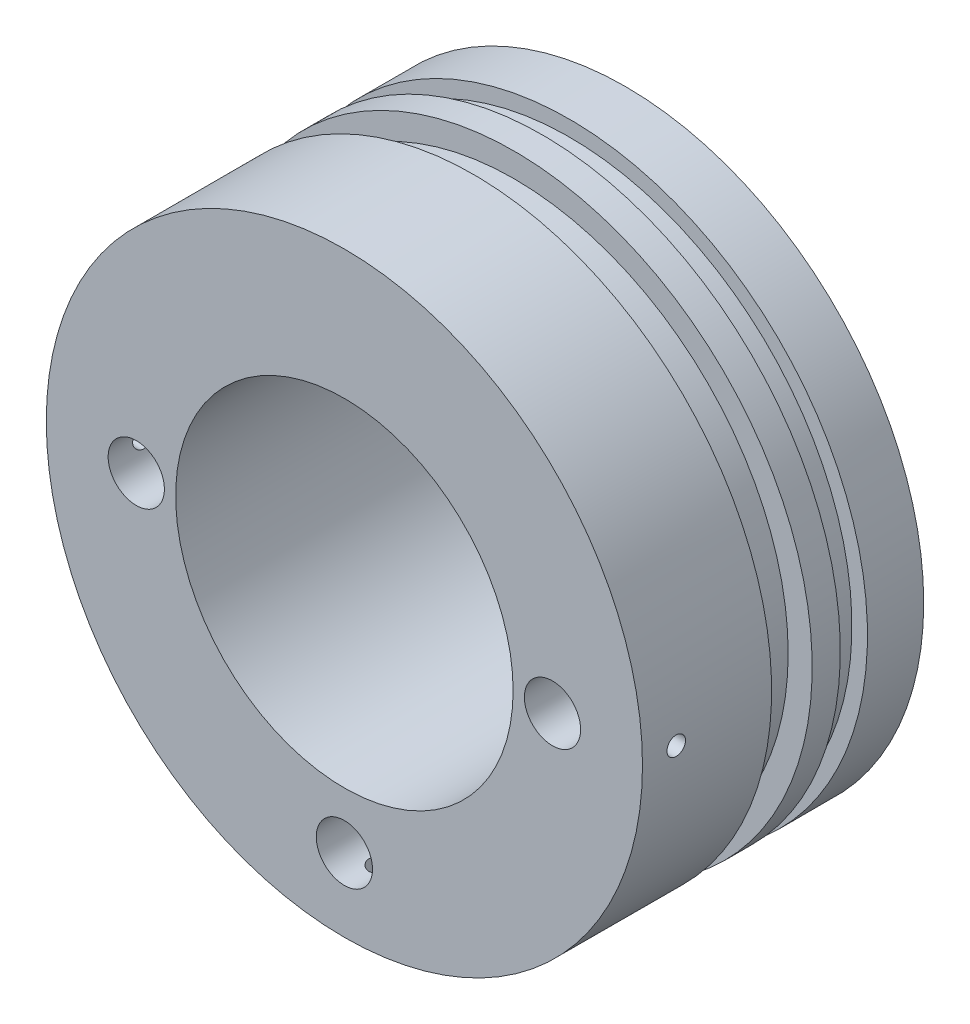
from build123d import *

# Parameters (mm, degrees)
SKETCH1_R                      = 53
BOSS_EXTRUDE1_DEPTH            = 50
F_10_0_10_DIAMETER_HOLE2_D     = 10
F_10_0_10_DIAMETER_HOLE2_DEPTH = 17.5
F_10_0_10_DIAMETER_HOLE2_TIP   = 3.004303095
M4_TAPPED_HOLE1_REACH          = 130.627
M4_TAPPED_HOLE1_BORE_R         = 1.65
CIRPATTERN1_COUNT              = 3
CIRPATTERN1_ANGLE              = 180
SKETCH11_R                     = 30
CUT_EXTRUDE2_DEPTH             = 45
SKETCH12_W                     = 4.826
SKETCH12_H                     = 2.76515
SKETCH12_W_2                   = 7.2136
SKETCH12_H_2                   = 4.27264
SKETCH14_W                     = 2.667
SKETCH14_H                     = 4.572
CIRPATTERN2_COUNT              = 4


with BuildPart() as part:
    # Sketch1 → Boss-Extrude1 (new body)
    with BuildSketch(Plane.XY):
        Circle(SKETCH1_R)
    extrude(amount=BOSS_EXTRUDE1_DEPTH)

    # Ø10.0 (10) Diameter Hole2
    with Locations(Plane.XY.offset(50)):
        with Locations((-37, 0), (37, 0), (0, -40)):
            Hole(F_10_0_10_DIAMETER_HOLE2_D / 2, depth=F_10_0_10_DIAMETER_HOLE2_DEPTH)
            with Locations((0, 0, -(F_10_0_10_DIAMETER_HOLE2_DEPTH + F_10_0_10_DIAMETER_HOLE2_TIP / 2))):  # 118° drill point
                Cone(0, F_10_0_10_DIAMETER_HOLE2_D / 2, F_10_0_10_DIAMETER_HOLE2_TIP, mode=Mode.SUBTRACT)

    # M4 Tapped Hole1 bore → M4 Tapped Hole1 (cut, up to next)
    with BuildSketch(Plane.ZY.offset(53), mode=Mode.PRIVATE) as m4_tapped_hole1_sk1:
        with Locations((44, 0)):
            Circle(M4_TAPPED_HOLE1_BORE_R)
    m4_tapped_hole1_tool1 = extrude(m4_tapped_hole1_sk1.sketch, amount=-M4_TAPPED_HOLE1_REACH, mode=Mode.PRIVATE) & part.part
    m4_tapped_hole1 = m4_tapped_hole1_tool1.solids().sort_by_distance((-53, 0, 44))[0]
    add(m4_tapped_hole1, mode=Mode.SUBTRACT)

    # CirPattern1: M4 Tapped Hole1 ×3 about axis
    cirpattern1_axis = Axis((0, 0, 50), (0, 0, 1))
    for i in range(1, CIRPATTERN1_COUNT):
        add(m4_tapped_hole1.rotate(cirpattern1_axis, i * CIRPATTERN1_ANGLE / (CIRPATTERN1_COUNT - 1)), mode=Mode.SUBTRACT)

    # Sketch11 → Cut-Extrude2 (cut)
    with BuildSketch(Plane.XY.offset(50)):
        Circle(SKETCH11_R)
    extrude(amount=-CUT_EXTRUDE2_DEPTH, mode=Mode.SUBTRACT)

    # Sketch12 → Cut-Revolve1 (revolve, cut)
    with BuildSketch(Plane(origin=(0, 0, 0), x_dir=(0, 0, -1), z_dir=(1, 0, 0)), mode=Mode.PRIVATE) as cut_revolve1_sk:
        with Locations((-12.413, 51.617425)):
            Rectangle(SKETCH12_W, SKETCH12_H)
        with Locations((-23.4328, 50.86368)):
            Rectangle(SKETCH12_W_2, SKETCH12_H_2)
    revolve(cut_revolve1_sk.sketch.rotate(Axis((0, 0, 0), (0, 0, 1)), 90), axis=Axis((0, 0, 0), (0, 0, 1)), mode=Mode.SUBTRACT)

    # Sketch14 → Cut-Revolve2 (revolve, cut)
    with BuildSketch(Plane(origin=(0, 0, 0), x_dir=(0, 0, -1), z_dir=(1, 0, 0)), mode=Mode.PRIVATE) as cut_revolve2_sk:
        with Locations((-1.3335, 24.8666)):
            Rectangle(SKETCH14_W, SKETCH14_H)
    revolve(cut_revolve2_sk.sketch.rotate(Axis((0, 0, 0), (0, 0, -1)), 270), axis=Axis((0, 0, 0), (0, 0, -1)), mode=Mode.SUBTRACT)

    # Sketch17 → M5 Tapped Hole1 (revolve, cut)
    with BuildSketch(Plane(origin=(-28.284271247, 28.284271247, 0), x_dir=(0, 1, 0), z_dir=(1, 0, 0))):
        Polygon((0, 0), (0, 15.2618073), (2.1, 14), (2.1, 0), align=None)
    m5_tapped_hole1 = revolve(axis=Axis((-28.284271247, 28.284271247, -6.35), (0, 0, 1)), mode=Mode.SUBTRACT)

    # CirPattern2: M5 Tapped Hole1 ×4 about axis
    cirpattern2_axis = Axis((0, 0, 0), (0, 0, 1))
    for i in range(1, CIRPATTERN2_COUNT):
        add(m5_tapped_hole1.rotate(cirpattern2_axis, i * 360 / CIRPATTERN2_COUNT), mode=Mode.SUBTRACT)


solid = part.part
